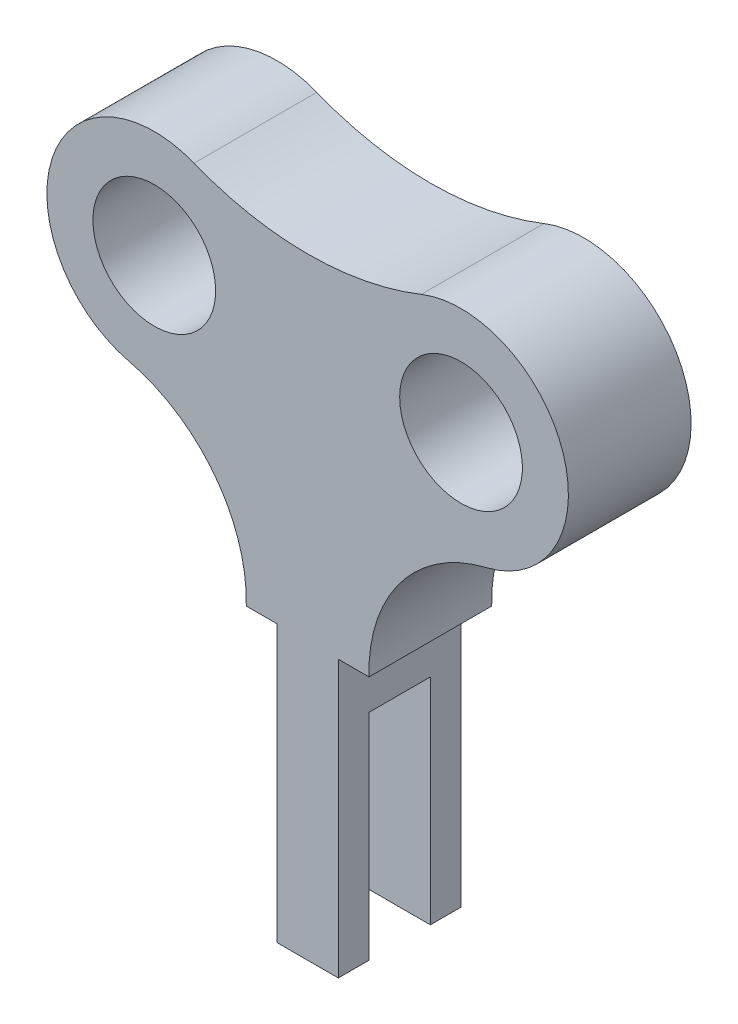
from build123d import *

# Parameters (mm, degrees)
BOSS_EXTRUDE1_DEPTH = 20
SKETCH3_W           = 10
SKETCH3_H           = 35
CUT_EXTRUDE1_DEPTH  = 48.5
SKETCH4_R           = 10
CUT_EXTRUDE2_DEPTH  = 21


with BuildPart() as part:
    # Sketch1 → Boss-Extrude1 (new body)
    with BuildSketch(Plane.XY):
        with BuildLine():
            Line((-5, -22.5), (5, -22.5))
            Line((5, -22.5), (5, 22.5))
            Line((5, 22.5), (10, 22.5))
            ThreePointArc((10, 22.5), (15.132819854, 38.37888203), (29.113715132, 47.490374848))
            ThreePointArc((29.113715132, 47.490374848), (41.674629404, 69.811001246), (18.518518519, 80.755472857))
            ThreePointArc((18.518518519, 80.755472857), (0, 77.19968102), (-18.518518519, 80.755472857))
            ThreePointArc((-18.518518519, 80.755472857), (-41.674629404, 69.811001246), (-29.113715132, 47.490374848))
            ThreePointArc((-29.113715132, 47.490374848), (-15.132819854, 38.37888203), (-10, 22.5))
            Line((-10, 22.5), (-5, 22.5))
            Line((-5, 22.5), (-5, -22.5))
        make_face()
    extrude(amount=BOSS_EXTRUDE1_DEPTH)

    # Sketch3 → Cut-Extrude1 (cut, through all)
    with BuildSketch(Plane(origin=(5, 0, 0), x_dir=(0, 0, -1), z_dir=(1, 0, 0))):
        with Locations((-10, -5)):
            Rectangle(SKETCH3_W, SKETCH3_H)
    extrude(amount=-CUT_EXTRUDE1_DEPTH, mode=Mode.SUBTRACT)

    # Sketch4 → Cut-Extrude2 (cut, through all)
    with BuildSketch(Plane(origin=(0, 0, 0), x_dir=(-1, 0, 0), z_dir=(0, 0, -1))):
        with Locations((-25, 64.5)):
            Circle(SKETCH4_R)
        with Locations((25, 64.5)):
            Circle(SKETCH4_R)
    extrude(amount=-CUT_EXTRUDE2_DEPTH, mode=Mode.SUBTRACT)


solid = part.part
